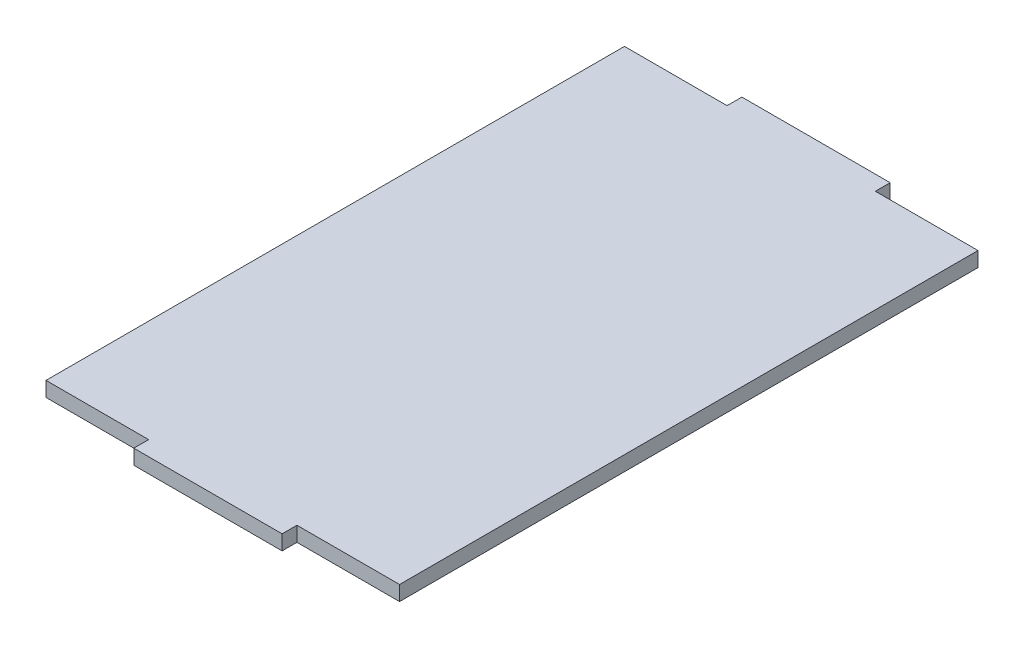
from build123d import *

# Parameters (mm, degrees)
BOSS_EXTRUDE1_DEPTH = 3


with BuildPart() as part:
    # Sketch1 → Boss-Extrude1 (new body)
    with BuildSketch(Plane(origin=(0, 0, 0), x_dir=(1, 0, 0), z_dir=(0, 1, 0))):
        Polygon((-17.401111732, 29.188327609), (12.598888268, 29.188327609), (12.598888268, 26.188327609), (33.353888268, 26.188327609), (33.353888268, -90.811672391), (12.598888268, -90.811672391), (12.598888268, -93.811672391), (-17.401111732, -93.811672391), (-17.401111732, -90.811672391), (-38.156111732, -90.811672391), (-38.156111732, 26.188327609), (-17.401111732, 26.188327609), align=None)
    extrude(amount=BOSS_EXTRUDE1_DEPTH)


solid = part.part
